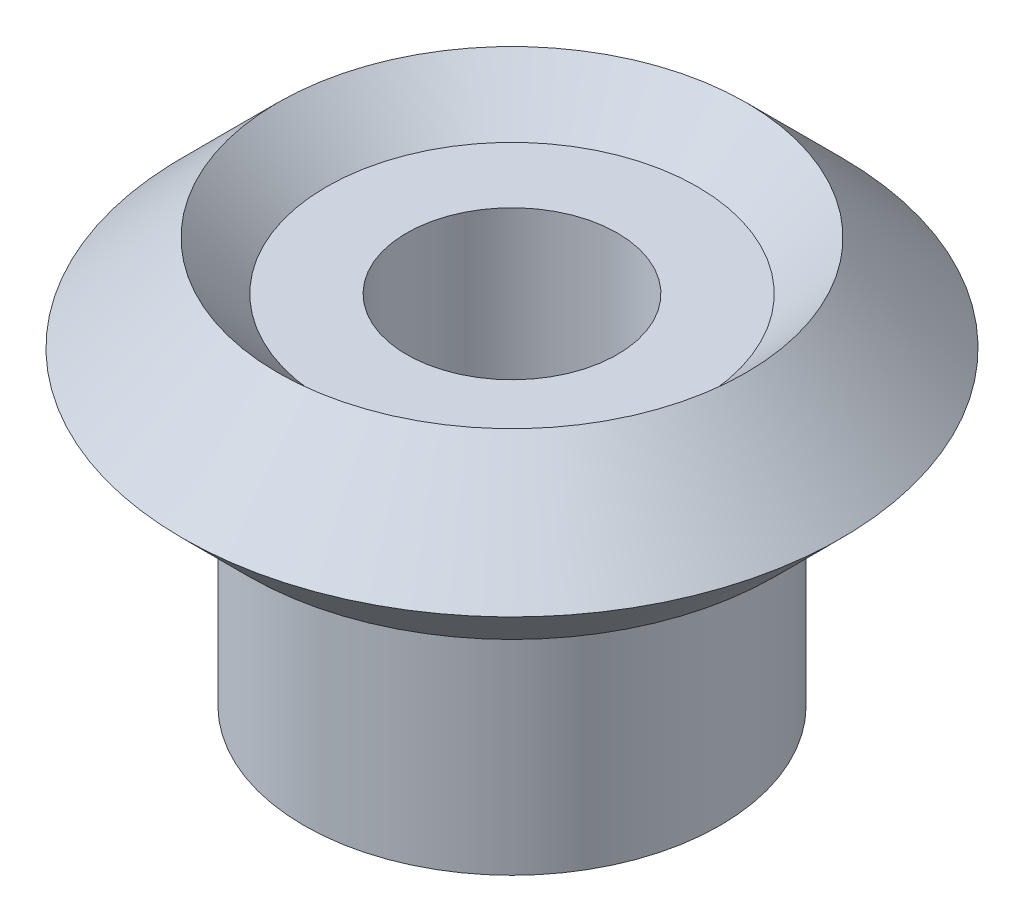
from build123d import *


with BuildPart() as part:
    # Sketch1 → Revolve1 (revolve)
    with BuildSketch(Plane.XY):
        Polygon((1.95, 0), (1.95, 6.6), (3.432233047, 6.6), (4.332233047, 7.5), (6.1, 5.732233047), (4.867766953, 4.5), (3.85, 4.5), (3.85, 0), align=None)
    revolve(axis=Axis((0, 0, 0), (0, 1, 0)))


solid = part.part
